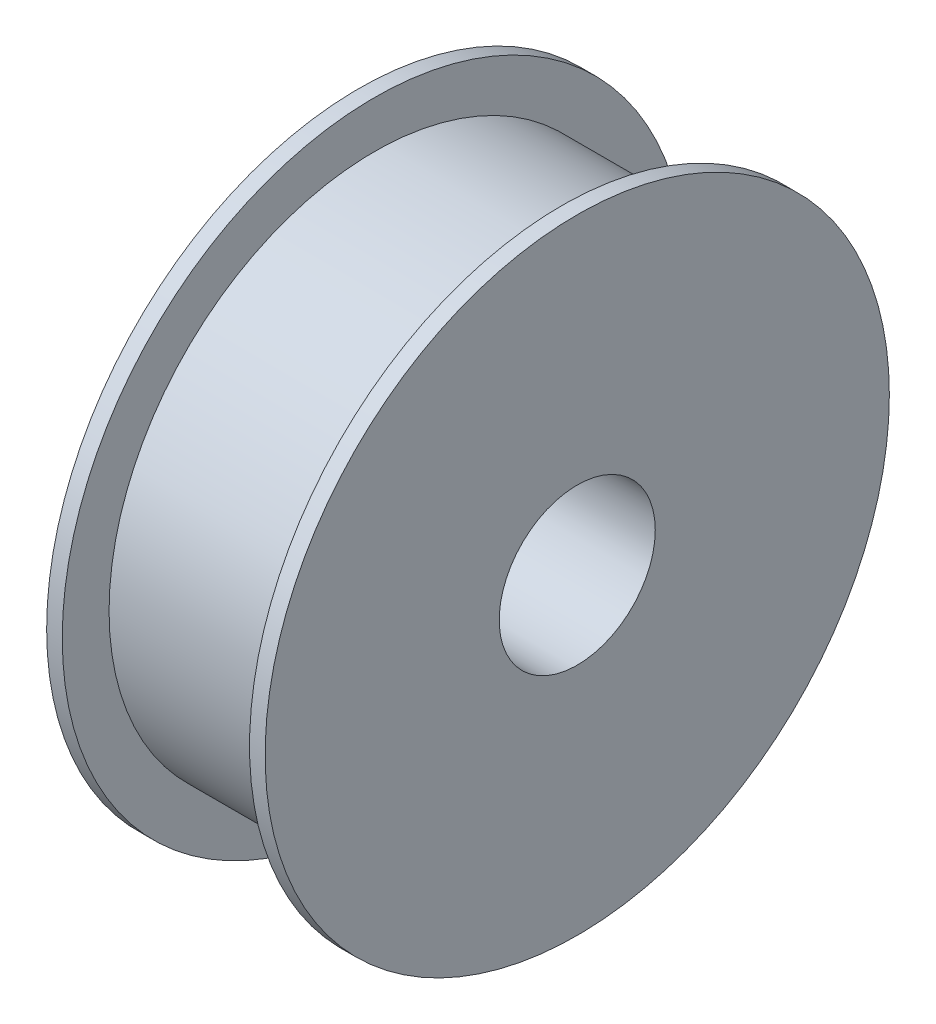
from build123d import *

# Parameters (mm, degrees)
CROQUIS1_R              = 100
CROQUIS1_R_2            = 25
SALIENTE_EXTRUIR1_DEPTH = 5
CROQUIS2_R              = 85
SALIENTE_EXTRUIR2_DEPTH = 60
CROQUIS3_R              = 100
SALIENTE_EXTRUIR3_DEPTH = 5
CROQUIS4_R              = 25
CORTAR_EXTRUIR1_DEPTH   = 65


with BuildPart() as part:
    # Croquis1 → Saliente-Extruir1 (new body)
    with BuildSketch(Plane(origin=(0, 0, 0), x_dir=(0, 0, -1), z_dir=(1, 0, 0))):
        Circle(CROQUIS1_R)
        Circle(CROQUIS1_R_2, mode=Mode.SUBTRACT)
    extrude(amount=SALIENTE_EXTRUIR1_DEPTH)

    # Croquis2 → Saliente-Extruir2 (add)
    with BuildSketch(Plane.ZY):
        Circle(CROQUIS2_R)
    extrude(amount=SALIENTE_EXTRUIR2_DEPTH)

    # Croquis3 → Saliente-Extruir3 (add)
    with BuildSketch(Plane.ZY.offset(60)):
        Circle(CROQUIS3_R)
    extrude(amount=SALIENTE_EXTRUIR3_DEPTH)

    # Croquis4 → Cortar-Extruir1 (cut)
    with BuildSketch(Plane(origin=(0, 0, 0), x_dir=(0, 0, -1), z_dir=(1, 0, 0))):
        Circle(CROQUIS4_R)
    extrude(amount=-CORTAR_EXTRUIR1_DEPTH, mode=Mode.SUBTRACT)


solid = part.part
